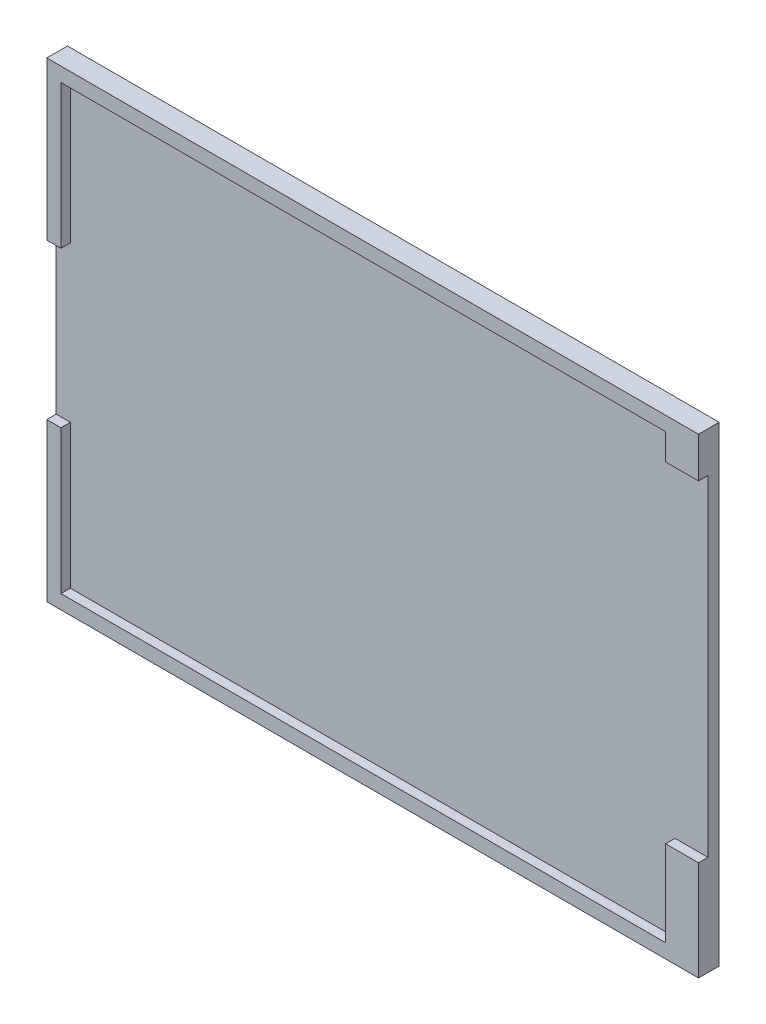
from build123d import *

# Parameters (mm, degrees)
ESQUISSE1_W             = 69.2
ESQUISSE1_H             = 50
BOSS_EXTRU_1_DEPTH      = 2.2
ENL_V_MAT_EXTRU_1_DEPTH = 1


with BuildPart() as part:
    # Esquisse1 → Boss.-Extru.1 (new body)
    with BuildSketch(Plane.XY):
        Rectangle(ESQUISSE1_W, ESQUISSE1_H)
    extrude(amount=BOSS_EXTRU_1_DEPTH)

    # Esquisse2 → Enlèv. mat.-Extru.1 (cut)
    with BuildSketch(Plane.XY.offset(2.2)):
        Polygon((34.6, 20.704314338), (31.104320123, 20.704314338), (31.104320123, 23.495586326), (-33.095389285, 23.495586326), (-33.095389285, 8.25), (-34.510836618, 8.25), (-34.6, 8.25), (-34.6, -8.25), (-33.095389285, -8.25), (-33.095389285, -23.5), (31.104320123, -23.5), (31.104320123, -14.404258976), (34.6, -14.404258976), align=None)
    extrude(amount=-ENL_V_MAT_EXTRU_1_DEPTH, mode=Mode.SUBTRACT)


solid = part.part
